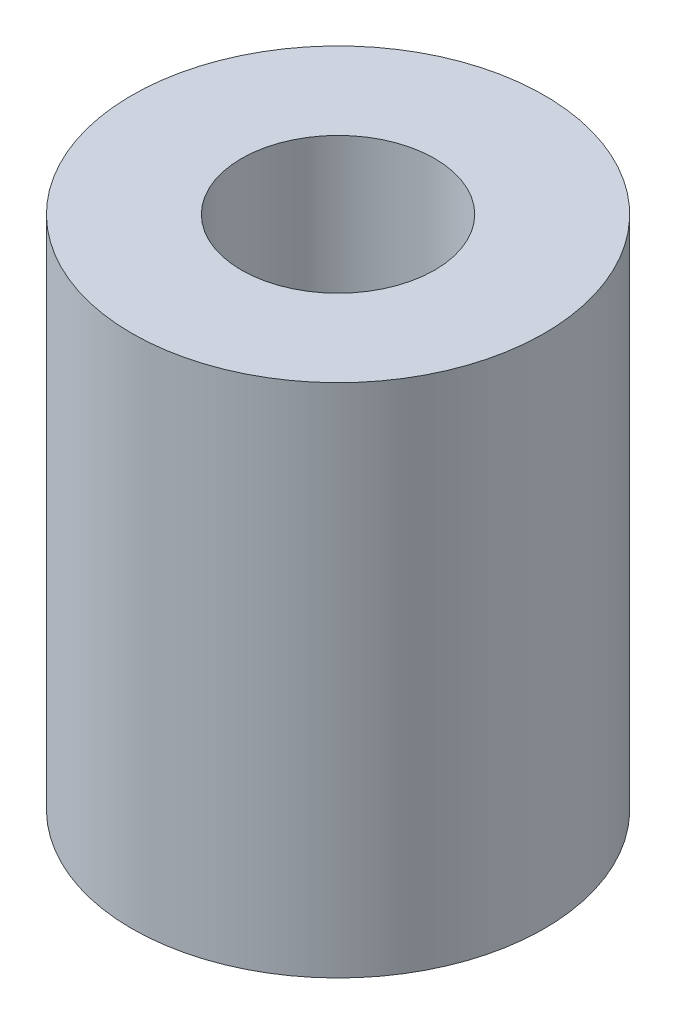
from build123d import *

# Parameters (mm, degrees)
SKETCH_1_R          = 16
SKETCH_1_R_2        = 7
EXTRUDE_1_DEPTH     = 40
SKETCH_3_R          = 7.5
CUT_EXTRUDE_1_DEPTH = 20


with BuildPart() as part:
    # 草图1 → 凸台-拉伸1 (new body)
    with BuildSketch(Plane(origin=(0, 0, 0), x_dir=(1, 0, 0), z_dir=(0, 1, 0))):
        Circle(SKETCH_1_R)
        Circle(SKETCH_1_R_2, mode=Mode.SUBTRACT)
    extrude(amount=EXTRUDE_1_DEPTH)

    # 草图3 → 切除-拉伸1 (cut)
    with BuildSketch(Plane(origin=(0, 40, 0), x_dir=(1, 0, 0), z_dir=(0, 1, 0))):
        Circle(SKETCH_3_R)
    extrude(amount=-CUT_EXTRUDE_1_DEPTH, mode=Mode.SUBTRACT)


solid = part.part
